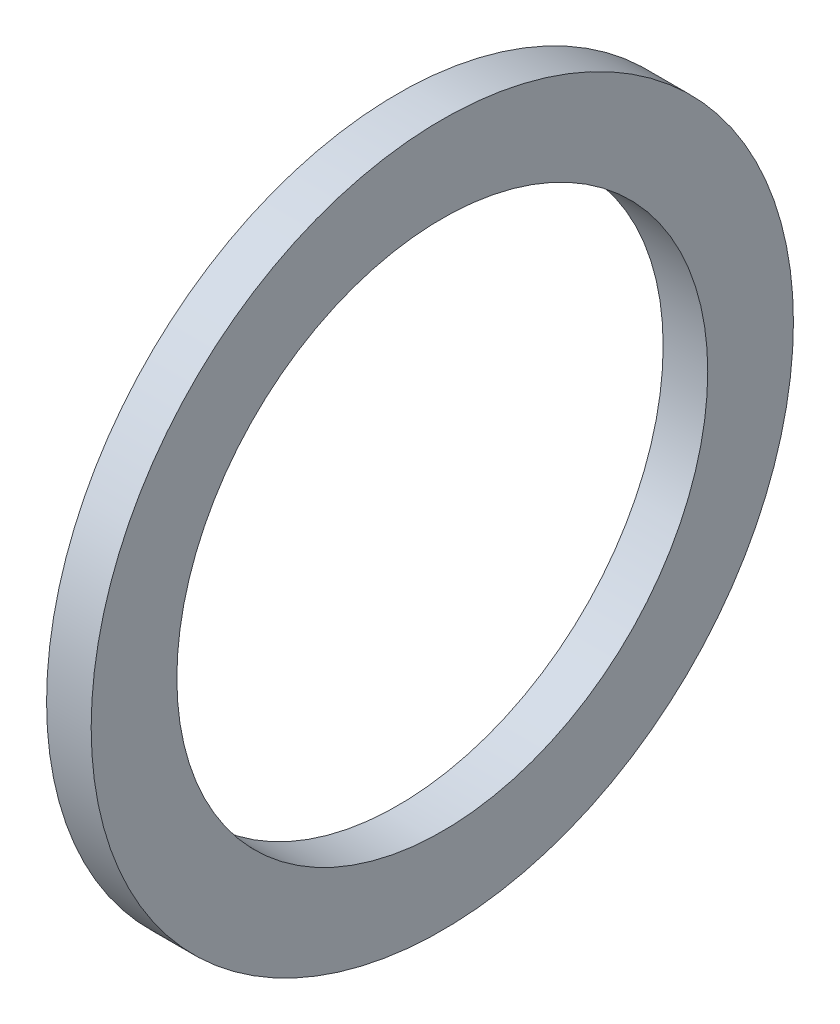
from build123d import *

# Parameters (mm, degrees)
SKETCH1_R           = 25
SKETCH1_R_2         = 18.9
BOSS_EXTRUDE1_DEPTH = 3.175


with BuildPart() as part:
    # Sketch1 → Boss-Extrude1 (new body)
    with BuildSketch(Plane(origin=(0, 0, 0), x_dir=(0, 0, -1), z_dir=(1, 0, 0))):
        Circle(SKETCH1_R)
        Circle(SKETCH1_R_2, mode=Mode.SUBTRACT)
    extrude(amount=BOSS_EXTRUDE1_DEPTH)


solid = part.part
